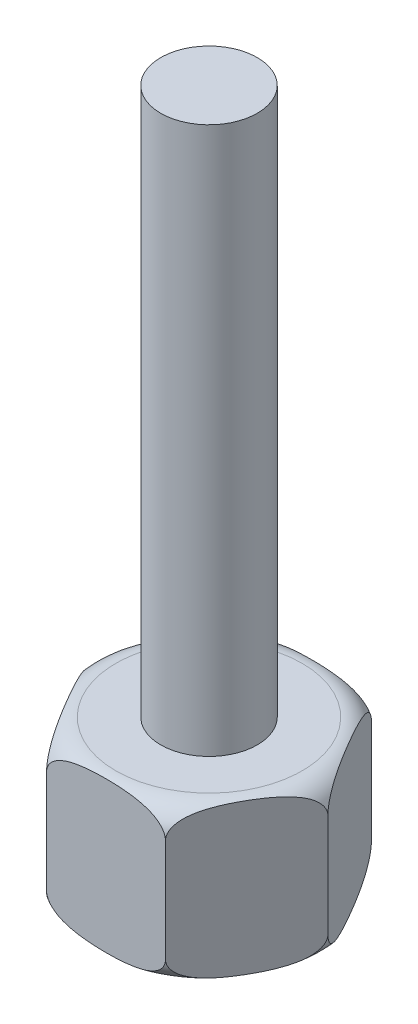
from build123d import *

# Parameters (mm, degrees)
BOSS_EXTRUDE1_DEPTH = 6
SKETCH2_R           = 1.875
BOSS_EXTRUDE2_DEPTH = 21.25


with BuildPart() as part:
    # Sketch1 → Boss-Extrude1 (new body)
    with BuildSketch(Plane(origin=(0, 0, 0), x_dir=(1, 0, 0), z_dir=(0, 1, 0))):
        Polygon((4.618802154, 0), (2.309401077, 4), (-2.309401077, 4), (-4.618802154, 0), (-2.309401077, -4), (2.309401077, -4), align=None)
    extrude(amount=BOSS_EXTRUDE1_DEPTH)

    # Sketch2 → Boss-Extrude2 (add)
    with BuildSketch(Plane(origin=(0, 6, 0), x_dir=(1, 0, 0), z_dir=(0, 1, 0))):
        Circle(SKETCH2_R)
    extrude(amount=BOSS_EXTRUDE2_DEPTH)

    # Sketch3 → Cut-Revolve1 (revolve, cut)
    with BuildSketch(Plane.XY):
        with BuildLine():
            Line((4.618802154, 0), (3.618802154, 0))
            ThreePointArc((3.618802154, 0), (4.325908935, 0.292893219), (4.618802154, 1))
            Line((4.618802154, 1), (4.618802154, 0))
        make_face()
        with BuildLine():
            Line((4.618802154, 5), (4.618802154, 6))
            Line((4.618802154, 6), (3.618802154, 6))
            ThreePointArc((3.618802154, 6), (4.325908935, 5.707106781), (4.618802154, 5))
        make_face()
    revolve(axis=Axis((0, 0, 0), (0, -1, 0)), mode=Mode.SUBTRACT)


solid = part.part
